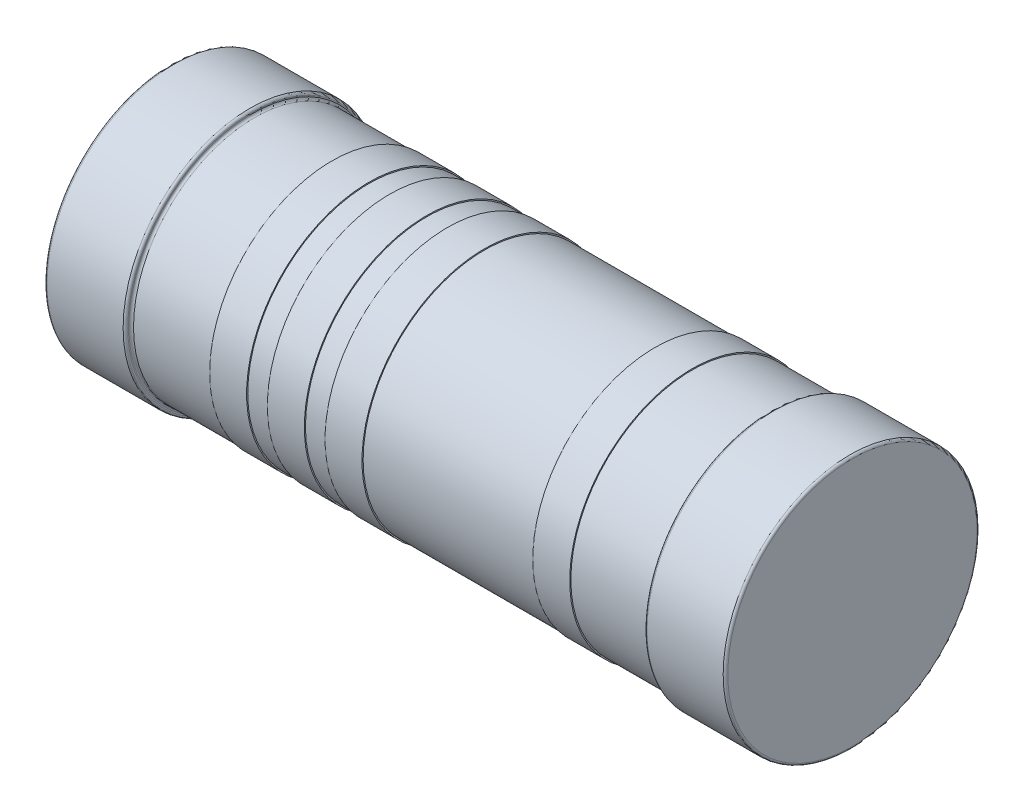
from build123d import *


with BuildPart() as part:
    # Sketch1 → Revolve1 (revolve)
    with BuildSketch(Plane.XY):
        with BuildLine():
            Line((-2.95, 1.1), (2.95, 1.1))
            Line((2.95, 1.1), (2.95, 0.02))
            ThreePointArc((2.95, 0.02), (2.944142136, 0.005857864), (2.93, 0))
            Line((2.93, 0), (2.27, 0))
            ThreePointArc((2.27, 0), (2.255857864, 0.005857864), (2.25, 0.02))
            Line((2.25, 0.02), (2.25, 0.03))
            ThreePointArc((2.25, 0.03), (2.244142136, 0.044142136), (2.23, 0.05))
            Line((2.23, 0.05), (1.56, 0.05))
            Line((1.56, 0.05), (1.56, 0.04))
            Line((1.56, 0.04), (1.24, 0.04))
            Line((1.24, 0.04), (1.24, 0.05))
            Line((1.24, 0.05), (-0.24, 0.05))
            Line((-0.24, 0.05), (-0.24, 0.04))
            Line((-0.24, 0.04), (-0.56, 0.04))
            Line((-0.56, 0.04), (-0.56, 0.05))
            Line((-0.56, 0.05), (-0.74, 0.05))
            Line((-0.74, 0.05), (-0.74, 0.04))
            Line((-0.74, 0.04), (-1.06, 0.04))
            Line((-1.06, 0.04), (-1.06, 0.05))
            Line((-1.06, 0.05), (-1.24, 0.05))
            Line((-1.24, 0.05), (-1.24, 0.04))
            Line((-1.24, 0.04), (-1.56, 0.04))
            Line((-1.56, 0.04), (-1.56, 0.05))
            Line((-1.56, 0.05), (-2.23, 0.05))
            ThreePointArc((-2.23, 0.05), (-2.244142136, 0.044142136), (-2.25, 0.03))
            Line((-2.25, 0.03), (-2.25, 0.02))
            ThreePointArc((-2.25, 0.02), (-2.255857864, 0.005857864), (-2.27, 0))
            Line((-2.27, 0), (-2.93, 0))
            ThreePointArc((-2.93, 0), (-2.944142136, 0.005857864), (-2.95, 0.02))
            Line((-2.95, 0.02), (-2.95, 1.1))
        make_face()
    revolve(axis=Axis((-2.95, 1.1, 0), (-1, 0, 0)))


solid = part.part
